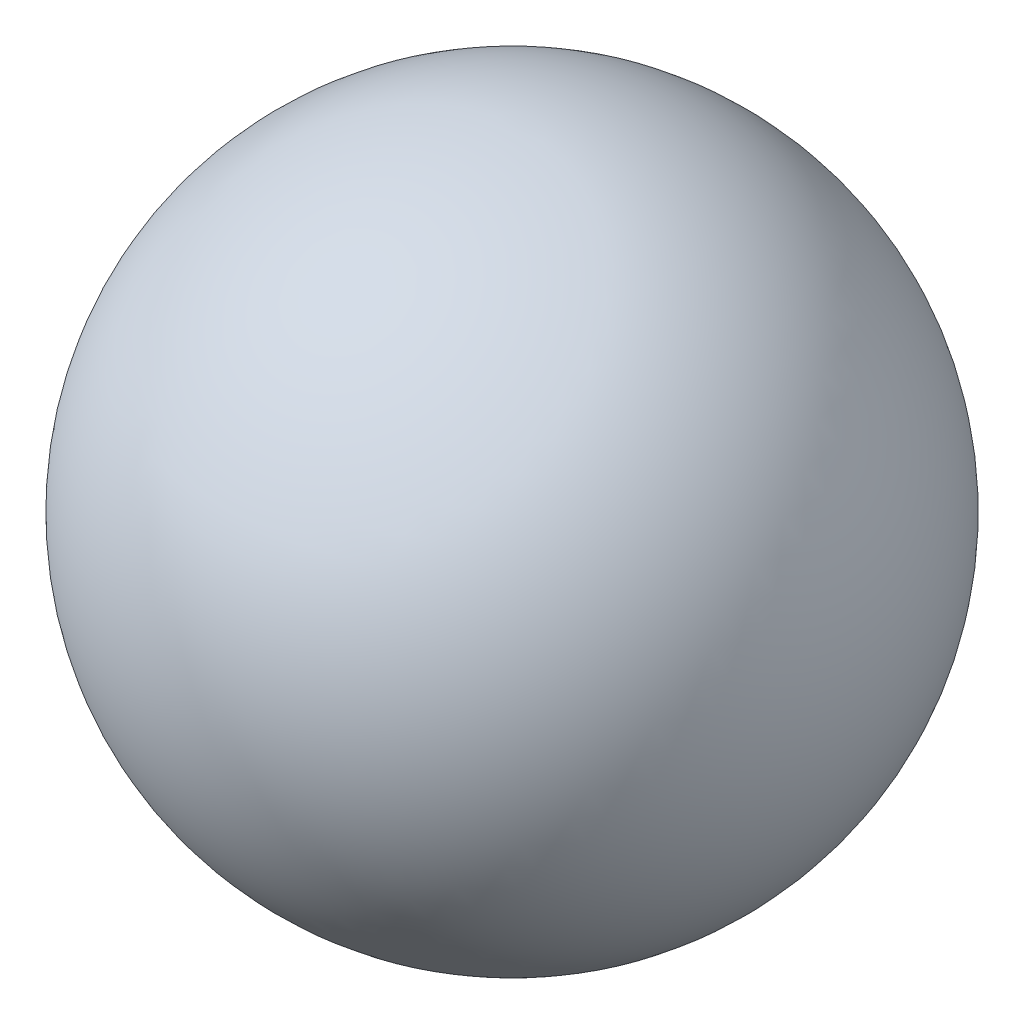
from build123d import *


with BuildPart() as part:
    # Sketch1 → Revolve1 (revolve)
    with BuildSketch(Plane.XY):
        with BuildLine():
            Line((0, 0.5), (0, -0.5))
            ThreePointArc((0, -0.5), (0.5, 0), (0, 0.5))
        make_face()
    revolve(axis=Axis((0, 0.5, 0), (0, -1, 0)))


solid = part.part
